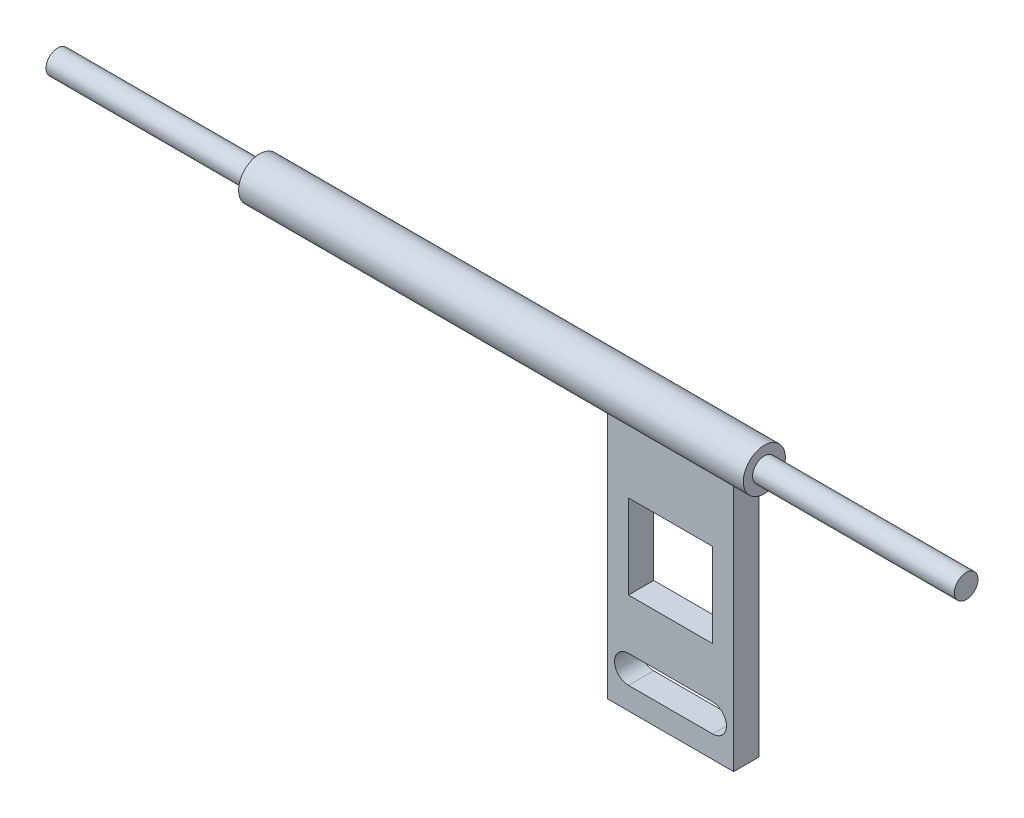
from build123d import *

# Parameters (mm, degrees)
SKETCH1_R                = 1.4
BOSS_EXTRUDE1_DEPTH      = 24
SKETCH2_R                = 2.5
BOSS_EXTRUDE2_DEPTH      = 60
SKETCH3_R                = 1.4
BOSS_EXTRUDE3_DEPTH      = 24
BOSS_EXTRUDE4_DEPTH      = 1.5
BOSS_EXTRUDE4_DEPTH_BACK = 1.5
SKETCH4_W                = 15
SKETCH4_H                = 30
CUT_EXTRUDE1_DEPTH       = 10
CUT_EXTRUDE1_DEPTH_BACK  = 7
SKETCH5_W                = 10
SKETCH5_H                = 10


with BuildPart() as part:
    # Sketch1 → Boss-Extrude1 (new body)
    with BuildSketch(Plane(origin=(0, 0, 0), x_dir=(0, 0, -1), z_dir=(1, 0, 0))):
        Circle(SKETCH1_R)
    extrude(amount=BOSS_EXTRUDE1_DEPTH)

    # Sketch2 → Boss-Extrude2 (add)
    with BuildSketch(Plane(origin=(24, 0, 0), x_dir=(0, 0, -1), z_dir=(1, 0, 0))):
        Circle(SKETCH2_R)
    extrude(amount=BOSS_EXTRUDE2_DEPTH)

    # Sketch3 → Boss-Extrude3 (add)
    with BuildSketch(Plane(origin=(84, 0, 0), x_dir=(0, 0, -1), z_dir=(1, 0, 0))):
        Circle(SKETCH3_R)
    extrude(amount=BOSS_EXTRUDE3_DEPTH)

    # Sketch4 → Boss-Extrude4 (add, two sides: drawn at the far end of the back side and taken through both)
    with BuildSketch(Plane.XY.offset(-BOSS_EXTRUDE4_DEPTH_BACK)):
        with Locations((74.346083047, -16.435117581)):
            Rectangle(SKETCH4_W, SKETCH4_H)
    extrude(amount=BOSS_EXTRUDE4_DEPTH + BOSS_EXTRUDE4_DEPTH_BACK)

    # Sketch5 → Cut-Extrude1 (cut, two sides: drawn at the far end of the back side and taken through both)
    with BuildSketch(Plane(origin=(0, 0, -1.5), x_dir=(-1, 0, 0), z_dir=(0, 0, -1)).offset(-CUT_EXTRUDE1_DEPTH_BACK)):
        with Locations((-74.346083047, -14.5)):
            Rectangle(SKETCH5_W, SKETCH5_H)
        with BuildLine():
            Line((-79.346083047, -25.5), (-69.346083047, -25.5))
            ThreePointArc((-69.346083047, -25.5), (-67.696083047, -27.15), (-69.346083047, -28.8))
            Line((-69.346083047, -28.8), (-79.346083047, -28.8))
            ThreePointArc((-79.346083047, -28.8), (-80.996083047, -27.15), (-79.346083047, -25.5))
        make_face()
    extrude(amount=CUT_EXTRUDE1_DEPTH + CUT_EXTRUDE1_DEPTH_BACK, mode=Mode.SUBTRACT)


solid = part.part
